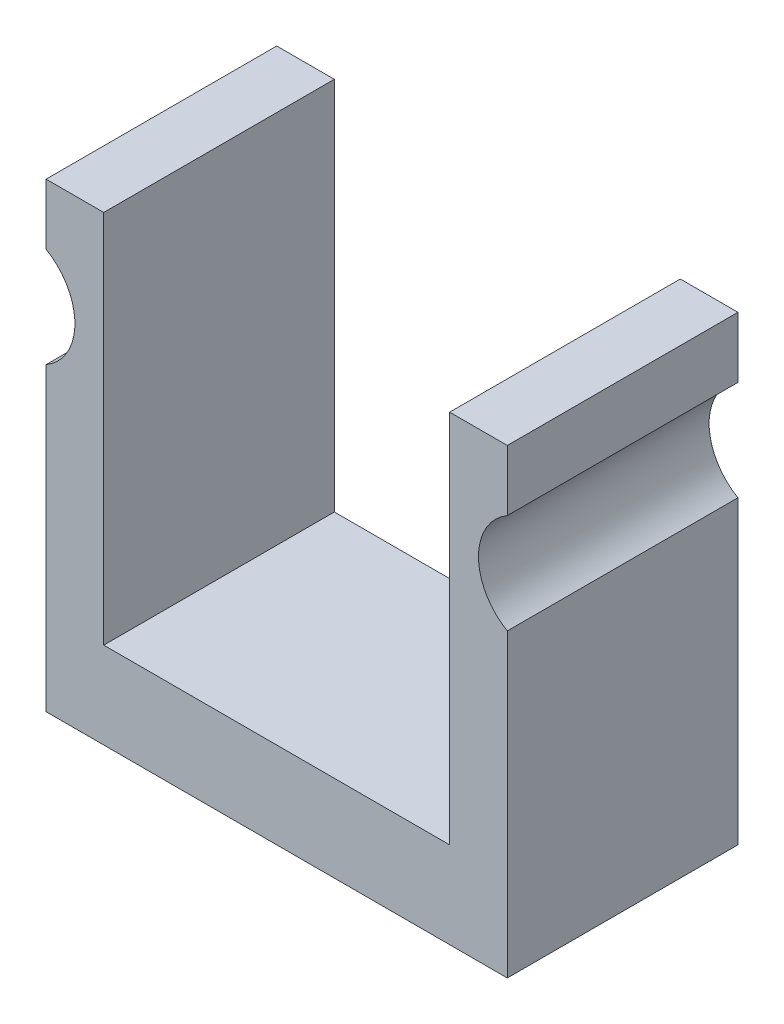
from build123d import *

# Parameters (mm, degrees)
BOSS_EXTRUDE1_DEPTH = 25.4
SKETCH2_R           = 6.35
CUT_EXTRUDE1_DEPTH  = 25.4


with BuildPart() as part:
    # Sketch1 → Boss-Extrude1 (new body)
    with BuildSketch(Plane.XY):
        Polygon((-34.042504308, -19.37463512), (16.757495692, -19.37463512), (16.757495692, 31.42536488), (10.407495692, 31.42536488), (10.407495692, -9.84963512), (-27.692504308, -9.84963512), (-27.692504308, 31.42536488), (-34.042504308, 31.42536488), align=None)
    extrude(amount=BOSS_EXTRUDE1_DEPTH)

    # Sketch2 → Cut-Extrude1 (cut)
    with BuildSketch(Plane.XY.offset(25.4)):
        with Locations((-37.217504308, 19.23336488)):
            Circle(SKETCH2_R)
        with Locations((19.932495692, 19.23336488)):
            Circle(SKETCH2_R)
    extrude(amount=-CUT_EXTRUDE1_DEPTH, mode=Mode.SUBTRACT)


solid = part.part
